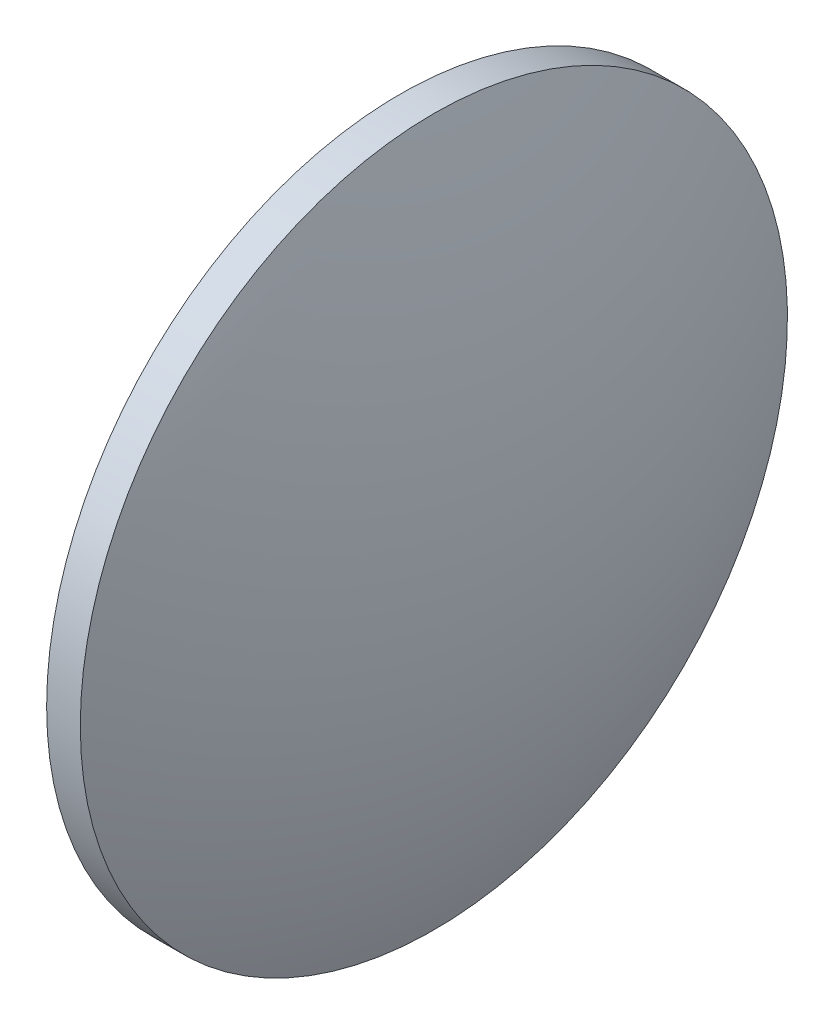
from build123d import *


with BuildPart() as part:
    # 草图1 → 旋转1 (revolve)
    with BuildSketch(Plane.XY):
        with BuildLine():
            Line((452.611017203, 80.821321086), (452.611017203, 112.321321086))
            Line((452.611017203, 112.321321086), (455.611017203, 112.321321086))
            ThreePointArc((455.611017203, 112.321321086), (460.276006046, 96.877376019), (461.851017203, 80.821321086))
            Line((461.851017203, 80.821321086), (452.611017203, 80.821321086))
        make_face()
    revolve(axis=Axis((444.640285536, 80.821321086, 0), (1, 0, 0)))


solid = part.part
